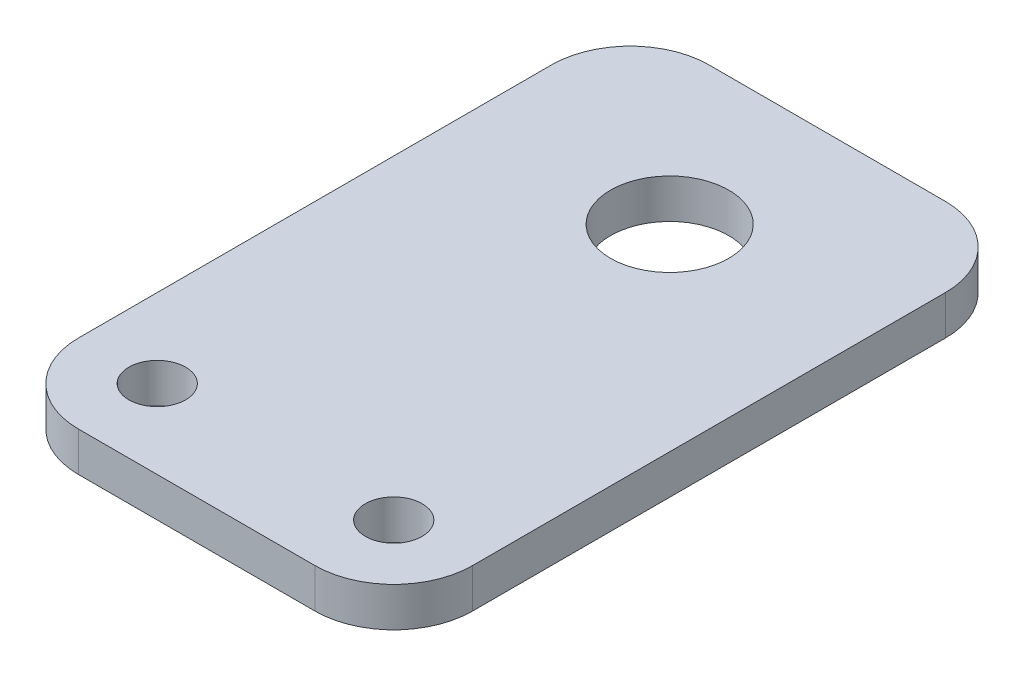
from build123d import *

# Parameters (mm, degrees)
SKETCH1_W           = 31.75
SKETCH1_H           = 50.8
SKETCH1_R           = 4.7625
SKETCH1_R_2         = 2.286
BOSS_EXTRUDE1_DEPTH = 3.175
FILLET1_R           = 6.35


with BuildPart() as part:
    # Sketch1 → Boss-Extrude1 (new body)
    with BuildSketch(Plane(origin=(0, 0, 0), x_dir=(1, 0, 0), z_dir=(0, 1, 0))):
        with Locations((15.875, 25.4)):
            Rectangle(SKETCH1_W, SKETCH1_H)
        with Locations((15.875, 38.1)):
            Circle(SKETCH1_R, mode=Mode.SUBTRACT)
        with Locations((6.35, 6.35)):
            Circle(SKETCH1_R_2, mode=Mode.SUBTRACT)
        with Locations((25.4, 6.35)):
            Circle(SKETCH1_R_2, mode=Mode.SUBTRACT)
    extrude(amount=BOSS_EXTRUDE1_DEPTH)

    # Fillet1
    fillet1_edges = [part.edges().sort_by_distance(p)[0] for p in [
        (0, 1.5875, -50.8),
        (31.75, 1.5875, -50.8),
        (31.75, 1.5875, 0),
        (0, 1.5875, 0),
    ]]
    fillet(fillet1_edges, radius=FILLET1_R)


solid = part.part
